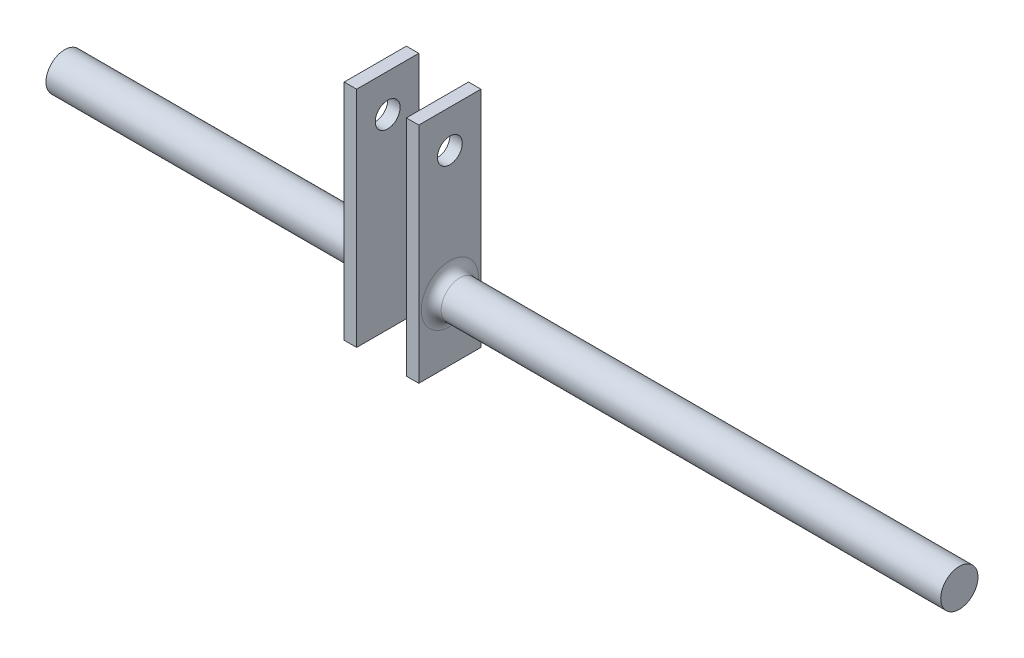
from build123d import *

# Parameters (mm, degrees)
SKETCH1_R               = 7.5
BOSS_EXTRUDE1_DEPTH     = 180
SKETCH2_W               = 30
SKETCH2_H               = 30
CUT_EXTRUDE1_DEPTH      = 180
SKETCH4_W               = 25
SKETCH4_H               = 90
BOSS_EXTRUDE2_DEPTH     = 5
SKETCH5_W               = 25
SKETCH5_H               = 90
BOSS_EXTRUDE3_DEPTH     = 5
SKETCH6_R               = 5
CUT_EXTRUDE2_DEPTH      = 126
CUT_EXTRUDE2_DEPTH_BACK = 236
FILLET1_R               = 4
FILLET2_R               = 4


with BuildPart() as part:
    # Sketch1 → Boss-Extrude1 (new body, symmetric)
    with BuildSketch(Plane(origin=(0, 0, 0), x_dir=(0, 0, -1), z_dir=(1, 0, 0))):
        Circle(SKETCH1_R)
    extrude(amount=BOSS_EXTRUDE1_DEPTH, both=True)

    # Sketch2 → Cut-Extrude1 (cut, symmetric)
    with BuildSketch(Plane.XY):
        with Locations((-40, 0)):
            Rectangle(SKETCH2_W, SKETCH2_H)
    extrude(amount=CUT_EXTRUDE1_DEPTH, both=True, mode=Mode.SUBTRACT)

    # Sketch4 → Boss-Extrude2 (add)
    with BuildSketch(Plane.ZY.offset(25)):
        with Locations((0, 20)):
            Rectangle(SKETCH4_W, SKETCH4_H)
    extrude(amount=BOSS_EXTRUDE2_DEPTH)

    # Sketch5 → Boss-Extrude3 (add)
    with BuildSketch(Plane(origin=(-55, 0, 0), x_dir=(0, 0, -1), z_dir=(1, 0, 0))):
        with Locations((0, 20)):
            Rectangle(SKETCH5_W, SKETCH5_H)
    extrude(amount=BOSS_EXTRUDE3_DEPTH)

    # Sketch6 → Cut-Extrude2 (cut, two sides)
    with BuildSketch(Plane.ZY.offset(55)) as cut_extrude2_sk:
        with Locations((0, 49.909918854)):
            Circle(SKETCH6_R)
    extrude(amount=CUT_EXTRUDE2_DEPTH, mode=Mode.SUBTRACT)
    extrude(cut_extrude2_sk.sketch, amount=-CUT_EXTRUDE2_DEPTH_BACK, mode=Mode.SUBTRACT)

    # Fillet1
    fillet1_edges = [part.edges().sort_by_distance(p)[0] for p in [
        (-55, 0, 7.5),
    ]]
    fillet(fillet1_edges, radius=FILLET1_R)

    # Fillet2
    fillet2_edges = [part.edges().sort_by_distance(p)[0] for p in [
        (-25, 0, 7.5),
    ]]
    fillet(fillet2_edges, radius=FILLET2_R)


solid = part.part
